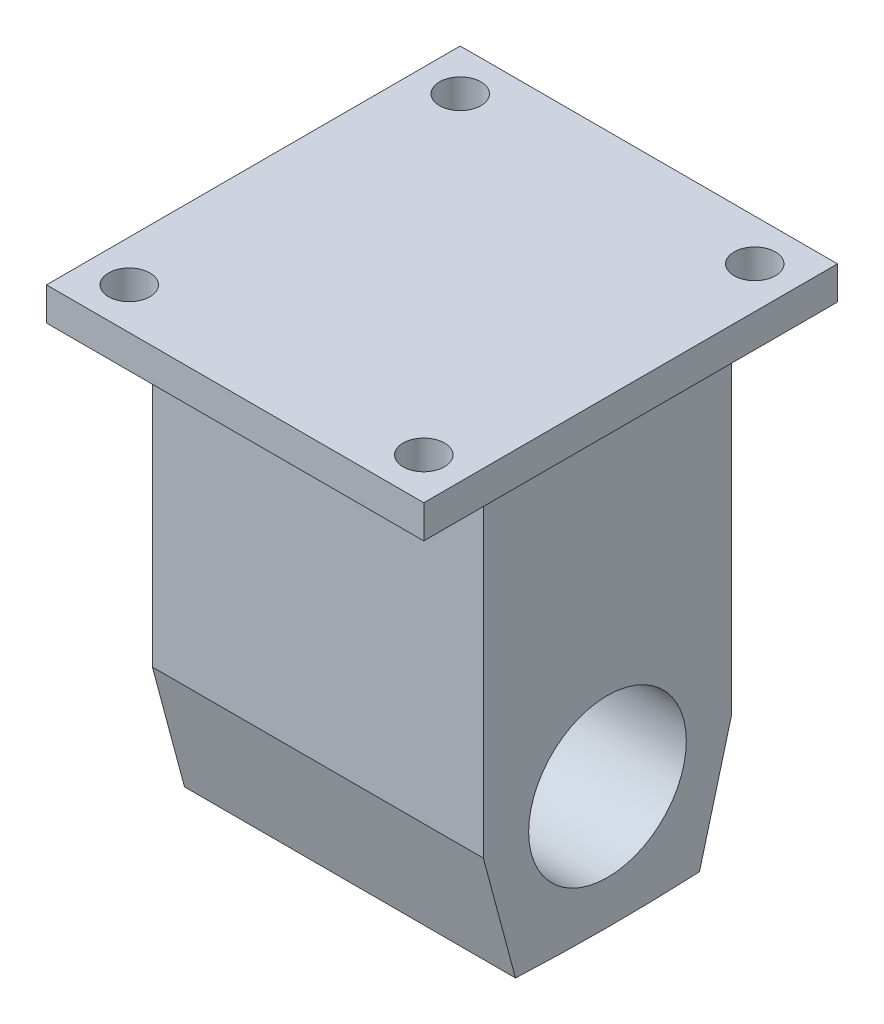
from build123d import *

# Parameters (mm, degrees)
SKETCH1_W           = 50.8
SKETCH1_H           = 38.1
BOSS_EXTRUDE1_DEPTH = 50.292
BOSS_EXTRUDE2_DEPTH = 50.8
SKETCH3_R           = 12.1
CUT_EXTRUDE1_DEPTH  = 127
SKETCH4_W           = 57.912
SKETCH4_H           = 63.5
BOSS_EXTRUDE3_DEPTH = 5.08
SKETCH5_R           = 3.175
CUT_EXTRUDE2_DEPTH  = 5.08


with BuildPart() as part:
    # Sketch1 → Boss-Extrude1 (new body)
    with BuildSketch(Plane(origin=(0, 0, 0), x_dir=(1, 0, 0), z_dir=(0, 1, 0))):
        Rectangle(SKETCH1_W, SKETCH1_H)
    extrude(amount=BOSS_EXTRUDE1_DEPTH)

    # Sketch2 → Boss-Extrude2 (add)
    with BuildSketch(Plane(origin=(25.4, 0, 0), x_dir=(0, 0, -1), z_dir=(1, 0, 0))):
        with BuildLine():
            Line((-19.05, 0), (-14.119497191, -18.400886991))
            ThreePointArc((-14.119497191, -18.400886991), (0, -18.733351542), (14.119497191, -18.400886991))
            Line((14.119497191, -18.400886991), (19.05, 0))
            Line((19.05, 0), (-19.05, 0))
        make_face()
    extrude(amount=-BOSS_EXTRUDE2_DEPTH)

    # Sketch3 → Cut-Extrude1 (cut)
    with BuildSketch(Plane(origin=(25.4, 0, 0), x_dir=(0, 0, -1), z_dir=(1, 0, 0))):
        Circle(SKETCH3_R)
    extrude(amount=-CUT_EXTRUDE1_DEPTH, mode=Mode.SUBTRACT)

    # Sketch4 → Boss-Extrude3 (add)
    with BuildSketch(Plane(origin=(0, 50.292, 0), x_dir=(1, 0, 0), z_dir=(0, 1, 0))):
        Rectangle(SKETCH4_W, SKETCH4_H)
    extrude(amount=BOSS_EXTRUDE3_DEPTH)

    # Sketch5 → Cut-Extrude2 (cut)
    with BuildSketch(Plane(origin=(0, 55.372, 0), x_dir=(1, 0, 0), z_dir=(0, 1, 0))):
        with Locations((-22.606, 25.4)):
            Circle(SKETCH5_R)
        with Locations((-22.606, -25.4)):
            Circle(SKETCH5_R)
        with Locations((22.606, 25.4)):
            Circle(SKETCH5_R)
        with Locations((22.606, -25.4)):
            Circle(SKETCH5_R)
    extrude(amount=-CUT_EXTRUDE2_DEPTH, mode=Mode.SUBTRACT)


solid = part.part
